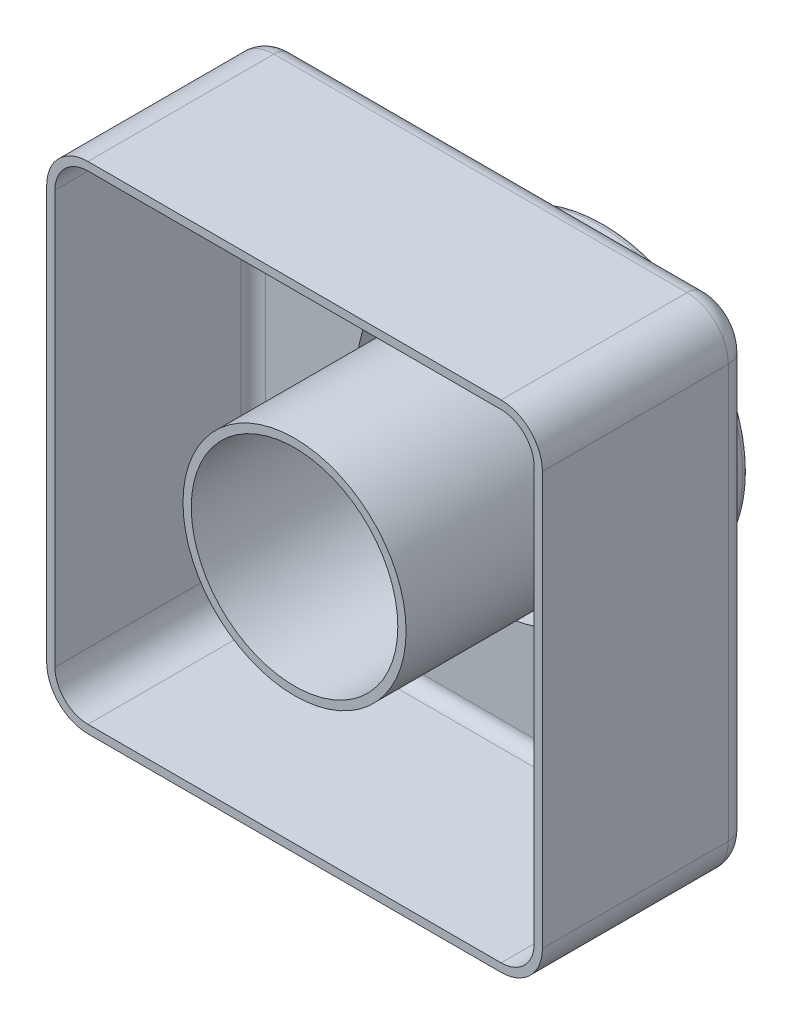
from build123d import *

# Parameters (mm, degrees)
SKETCH2_W           = 120
SKETCH2_H           = 120
BOSS_EXTRUDE1_DEPTH = 50
SKETCH3_R           = 35
BOSS_EXTRUDE2_DEPTH = 25
SKETCH4_R           = 25
CUT_EXTRUDE1_DEPTH  = 76
FILLET2_R           = 1.5
FILLET7_R           = 10
FILLET8_R           = 5
SHELL1_T            = -2


with BuildPart() as part:
    # Sketch2 → Boss-Extrude1 (new body)
    with BuildSketch(Plane.XY):
        Rectangle(SKETCH2_W, SKETCH2_H)
    extrude(amount=BOSS_EXTRUDE1_DEPTH)

    # Sketch3 → Boss-Extrude2 (add)
    with BuildSketch(Plane(origin=(0, 0, 0), x_dir=(-1, 0, 0), z_dir=(0, 0, -1))):
        Circle(SKETCH3_R)
    extrude(amount=BOSS_EXTRUDE2_DEPTH)

    # Sketch4 → Cut-Extrude1 (cut, through all)
    with BuildSketch(Plane(origin=(0, 0, -25), x_dir=(-1, 0, 0), z_dir=(0, 0, -1))):
        Circle(SKETCH4_R)
    extrude(amount=-CUT_EXTRUDE1_DEPTH, mode=Mode.SUBTRACT)

    # Fillet2
    fillet2_edges = [part.edges().sort_by_distance(p)[0] for p in [
        (35, 0, -25),
        (25, 0, -25),
    ]]
    fillet(fillet2_edges, radius=FILLET2_R)

    # Fillet7
    fillet7_edges = [part.edges().sort_by_distance(p)[0] for p in [
        (-60, 60, 25),
        (60, 60, 25),
        (60, -60, 25),
        (-60, -60, 25),
    ]]
    fillet(fillet7_edges, radius=FILLET7_R)

    # Fillet8
    fillet8_edges = [part.edges().sort_by_distance(p)[0] for p in [
        (0, -60, 0),
        (-60, 0, 0),
        (0, 60, 0),
        (60, 0, 0),
        (57.071067812, 57.071067812, 0),
        (-57.071067812, 57.071067812, 0),
        (57.071067812, -57.071067812, 0),
        (-57.071067812, -57.071067812, 0),
    ]]
    fillet(fillet8_edges, radius=FILLET8_R)

    # Shell1
    shell1_openings = [part.faces().sort_by_distance(p)[0] for p in [
        (-25, 0, 50),
    ]]
    offset(amount=SHELL1_T, openings=shell1_openings, kind=Kind.INTERSECTION)


solid = part.part
